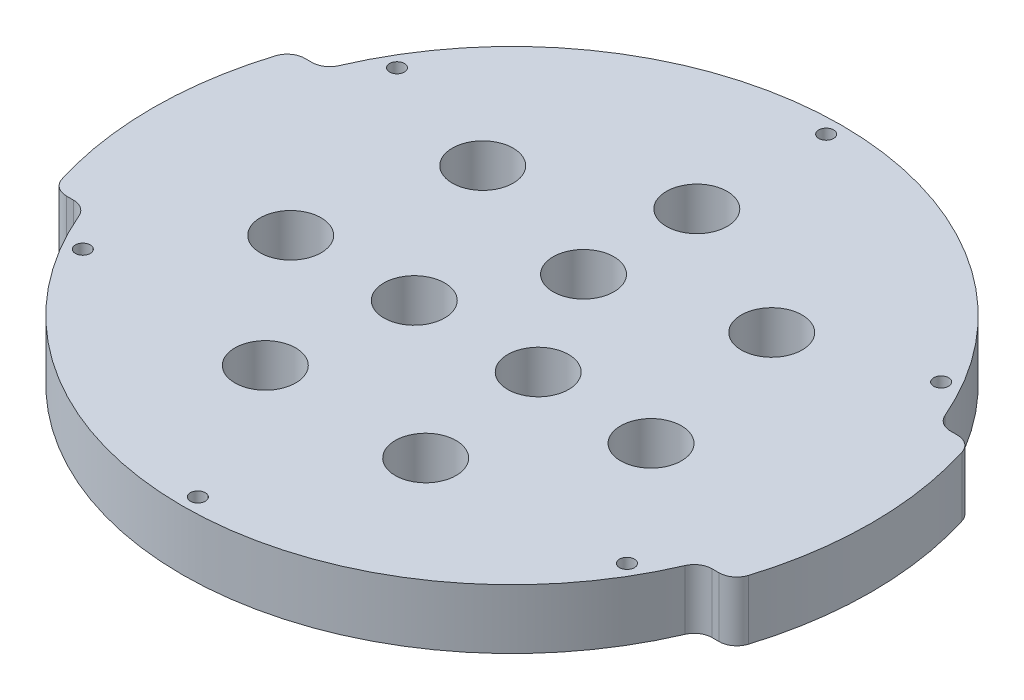
from build123d import *

# Parameters (mm, degrees)
SKETCH_3_R          = 60.3
EXTRUDE_2_DEPTH     = 10
CUT_EXTRUDE_2_DEPTH = 11
FILLET_1_R          = 3
SKETCH_5_R          = 1.25
CUT_EXTRUDE_3_DEPTH = 11
SKETCH_6_R          = 5.1
CUT_EXTRUDE_4_DEPTH = 11
SKETCH_7_R          = 5.1
CUT_EXTRUDE_5_DEPTH = 11


with BuildPart() as part:
    # 草图3 → 凸台-拉伸2 (new body)
    with BuildSketch(Plane(origin=(0, 0, 0), x_dir=(1, 0, 0), z_dir=(0, 1, 0))):
        Circle(SKETCH_3_R)
    extrude(amount=EXTRUDE_2_DEPTH)

    # 草图4 → 切除-拉伸2 (cut, through all)
    with BuildSketch(Plane(origin=(0, 10, 0), x_dir=(1, 0, 0), z_dir=(0, 1, 0))):
        with BuildLine():
            Line((-51.556667852, 20), (-56.886641666, 20))
            ThreePointArc((-56.886641666, 20), (0, 60.3), (56.886641666, 20))
            Line((56.886641666, 20), (51.556667852, 20))
            ThreePointArc((51.556667852, 20), (0, 55.3), (-51.556667852, 20))
        make_face()
        with BuildLine():
            Line((-56.886641666, -20), (-51.556667852, -20))
            ThreePointArc((-51.556667852, -20), (0, -55.3), (51.556667852, -20))
            Line((51.556667852, -20), (56.886641666, -20))
            ThreePointArc((56.886641666, -20), (0, -60.3), (-56.886641666, -20))
        make_face()
    extrude(amount=-CUT_EXTRUDE_2_DEPTH, mode=Mode.SUBTRACT)

    # 圆角1
    fillet_1_edges = [part.edges().sort_by_distance(p)[0] for p in [
        (51.556667852, 5, -20),
        (-51.556667852, 5, -20),
        (-56.886641666, 5, -20),
        (56.886641666, 5, -20),
        (-51.556667852, 5, 20),
        (51.556667852, 5, 20),
        (56.886641666, 5, 20),
        (-56.886641666, 5, 20),
    ]]
    fillet(fillet_1_edges, radius=FILLET_1_R)

    # 草图5 → 切除-拉伸3 (cut, through all)
    with BuildSketch(Plane.XZ):
        with Locations((0, -52.7)):
            Circle(SKETCH_5_R)
        with Locations((-45.639538779, -26.35)):
            Circle(SKETCH_5_R)
        with Locations((-45.639538779, 26.35)):
            Circle(SKETCH_5_R)
        with Locations((0, 52.7)):
            Circle(SKETCH_5_R)
        with Locations((45.639538779, 26.35)):
            Circle(SKETCH_5_R)
        with Locations((45.639538779, -26.35)):
            Circle(SKETCH_5_R)
    extrude(amount=-CUT_EXTRUDE_3_DEPTH, mode=Mode.SUBTRACT)

    # 草图6 → 切除-拉伸4 (cut, through all)
    with BuildSketch(Plane(origin=(0, 10, 0), x_dir=(1, 0, 0), z_dir=(0, 1, 0))):
        with Locations((0, 31)):
            Circle(SKETCH_6_R)
        with Locations((24.236775957, 19.328183858)):
            Circle(SKETCH_6_R)
        with Locations((30.222765278, -6.898148953)):
            Circle(SKETCH_6_R)
        with Locations((13.450395913, -27.930034905)):
            Circle(SKETCH_6_R)
        with Locations((-13.450395913, -27.930034905)):
            Circle(SKETCH_6_R)
        with Locations((-30.222765278, -6.898148953)):
            Circle(SKETCH_6_R)
        with Locations((-24.236775957, 19.328183858)):
            Circle(SKETCH_6_R)
    extrude(amount=-CUT_EXTRUDE_4_DEPTH, mode=Mode.SUBTRACT)

    # 草图7 → 切除-拉伸5 (cut, through all)
    with BuildSketch(Plane(origin=(0, 10, 0), x_dir=(1, 0, 0), z_dir=(0, 1, 0))):
        with Locations((0, 12)):
            Circle(SKETCH_7_R)
        with Locations((10.392304845, -6)):
            Circle(SKETCH_7_R)
        with Locations((-10.392304845, -6)):
            Circle(SKETCH_7_R)
    extrude(amount=-CUT_EXTRUDE_5_DEPTH, mode=Mode.SUBTRACT)


solid = part.part
